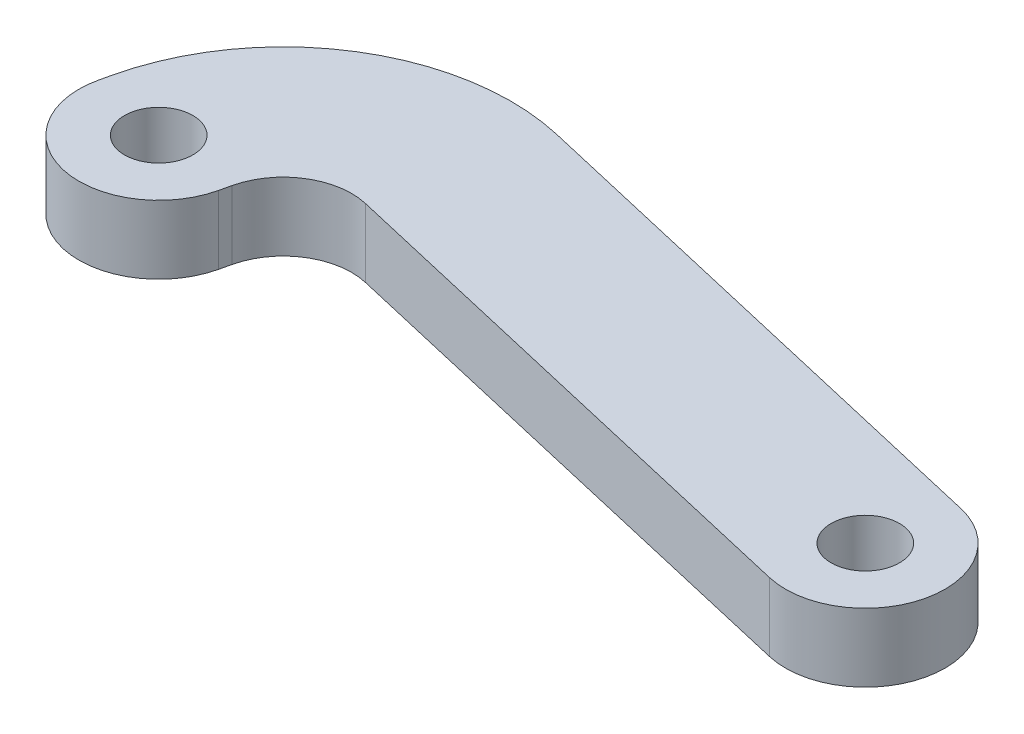
from build123d import *

# Parameters (mm, degrees)
SKETCH1_R           = 1.5
BOSS_EXTRUDE1_DEPTH = 3


with BuildPart() as part:
    # Sketch1 → Boss-Extrude1 (new body)
    with BuildSketch(Plane(origin=(0, 0, 0), x_dir=(1, 0, 0), z_dir=(0, 1, 0))):
        with BuildLine():
            Line((3.409602648, -0.790322581), (3.522505874, -0.303236488))
            ThreePointArc((3.522505874, -0.303236488), (4.857498975, 1.564883251), (7.122441784, 1.941860713))
            Line((7.122441784, 1.941860713), (30.209677419, -3.409602648))
            ThreePointArc((30.209677419, -3.409602648), (34.409602648, -0.790322581), (31.790322581, 3.409602648))
            Line((31.790322581, 3.409602648), (8.703086946, 8.761066009))
            ThreePointArc((8.703086946, 8.761066009), (1.153277579, 7.504474471), (-3.296699422, 1.277408673))
            Line((-3.296699422, 1.277408673), (-3.409602648, 0.790322581))
            ThreePointArc((-3.409602648, 0.790322581), (-0.790322581, -3.409602648), (3.409602648, -0.790322581))
        make_face()
        Circle(SKETCH1_R, mode=Mode.SUBTRACT)
        with Locations((31, 0)):
            Circle(SKETCH1_R, mode=Mode.SUBTRACT)
    extrude(amount=BOSS_EXTRUDE1_DEPTH)


solid = part.part
